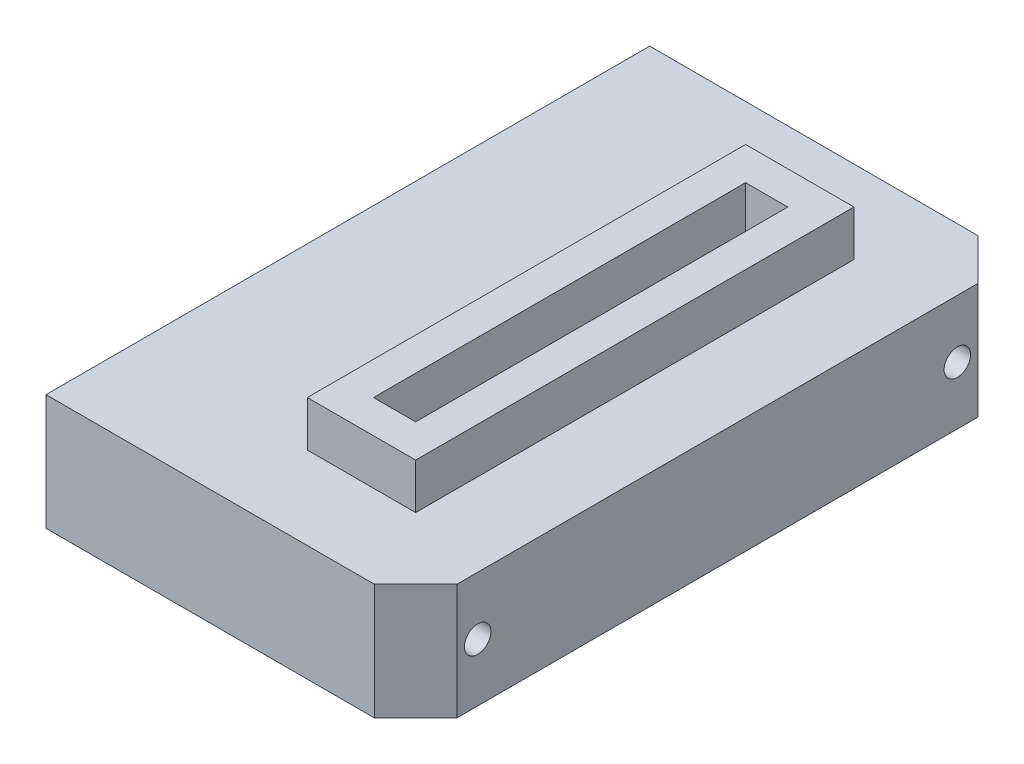
from build123d import *

# Parameters (mm, degrees)
SKETCH1_W           = 44.7
SKETCH1_H           = 73
SKETCH1_W_2         = 5.1
SKETCH1_H_2         = 45
BOSS_EXTRUDE1_DEPTH = 14
CUT_EXTRUDE1_REACH  = 46.7
SKETCH2_R           = 1.6
SKETCH3_W           = 13.1
SKETCH3_H           = 53
SKETCH3_W_2         = 5.1
SKETCH3_H_2         = 45
BOSS_EXTRUDE2_DEPTH = 5.5
CUT_EXTRUDE2_REACH  = 16


with BuildPart() as part:
    # Sketch1 → Boss-Extrude1 (new body)
    with BuildSketch(Plane(origin=(0, 0, 0), x_dir=(1, 0, 0), z_dir=(0, 1, 0))):
        with Locations((0.284066801, -8.539694425)):
            Rectangle(SKETCH1_W, SKETCH1_H)
        with Locations((6.084066801, -8.539694425)):
            Rectangle(SKETCH1_W_2, SKETCH1_H_2, mode=Mode.SUBTRACT)
    extrude(amount=BOSS_EXTRUDE1_DEPTH)

    # Sketch2 → Cut-Extrude1 (cut, up to next)
    with BuildSketch(Plane(origin=(22.634066801, 0, 0), x_dir=(0, 0, -1), z_dir=(1, 0, 0)), mode=Mode.PRIVATE) as cut_extrude1_sk1:
        with Locations((-37.539694425, 7)):
            Circle(SKETCH2_R)
    cut_extrude1_tool1 = extrude(cut_extrude1_sk1.sketch, amount=-CUT_EXTRUDE1_REACH, mode=Mode.PRIVATE) & part.part
    add(cut_extrude1_tool1.solids().sort_by_distance((22.634067, 7, 37.539694))[0], mode=Mode.SUBTRACT)
    # Sketch2 → Cut-Extrude1 (cut, up to next)
    with BuildSketch(Plane(origin=(22.634066801, 0, 0), x_dir=(0, 0, -1), z_dir=(1, 0, 0)), mode=Mode.PRIVATE) as cut_extrude1_sk2:
        with Locations((20.460305575, 7)):
            Circle(SKETCH2_R)
    cut_extrude1_tool2 = extrude(cut_extrude1_sk2.sketch, amount=-CUT_EXTRUDE1_REACH, mode=Mode.PRIVATE) & part.part
    add(cut_extrude1_tool2.solids().sort_by_distance((22.634067, 7, -20.460306))[0], mode=Mode.SUBTRACT)

    # Sketch3 → Boss-Extrude2 (add)
    with BuildSketch(Plane(origin=(0, 14, 0), x_dir=(1, 0, 0), z_dir=(0, 1, 0))):
        with Locations((6.084066801, -8.539694425)):
            Rectangle(SKETCH3_W, SKETCH3_H)
        with Locations((6.084066801, -8.539694425)):
            Rectangle(SKETCH3_W_2, SKETCH3_H_2, mode=Mode.SUBTRACT)
    extrude(amount=BOSS_EXTRUDE2_DEPTH)

    # Sketch4 → Cut-Extrude2 (cut, up to next)
    with BuildSketch(Plane(origin=(0, 14, 0), x_dir=(1, 0, 0), z_dir=(0, 1, 0)), mode=Mode.PRIVATE) as cut_extrude2_sk1:
        Polygon((17.634066801, 27.960305575), (22.634066801, 22.960305575), (22.634066801, 27.960305575), align=None)
    cut_extrude2_tool1 = extrude(cut_extrude2_sk1.sketch, amount=-CUT_EXTRUDE2_REACH, mode=Mode.PRIVATE) & part.part
    add(cut_extrude2_tool1.solids().sort_by_distance((20.9674, 14, -26.293639))[0], mode=Mode.SUBTRACT)
    # Sketch4 → Cut-Extrude2 (cut, up to next)
    with BuildSketch(Plane(origin=(0, 14, 0), x_dir=(1, 0, 0), z_dir=(0, 1, 0)), mode=Mode.PRIVATE) as cut_extrude2_sk2:
        Polygon((17.634066801, -45.039694425), (22.634066801, -40.039694425), (22.634066801, -45.039694425), align=None)
    cut_extrude2_tool2 = extrude(cut_extrude2_sk2.sketch, amount=-CUT_EXTRUDE2_REACH, mode=Mode.PRIVATE) & part.part
    add(cut_extrude2_tool2.solids().sort_by_distance((20.9674, 14, 43.373028))[0], mode=Mode.SUBTRACT)


solid = part.part
